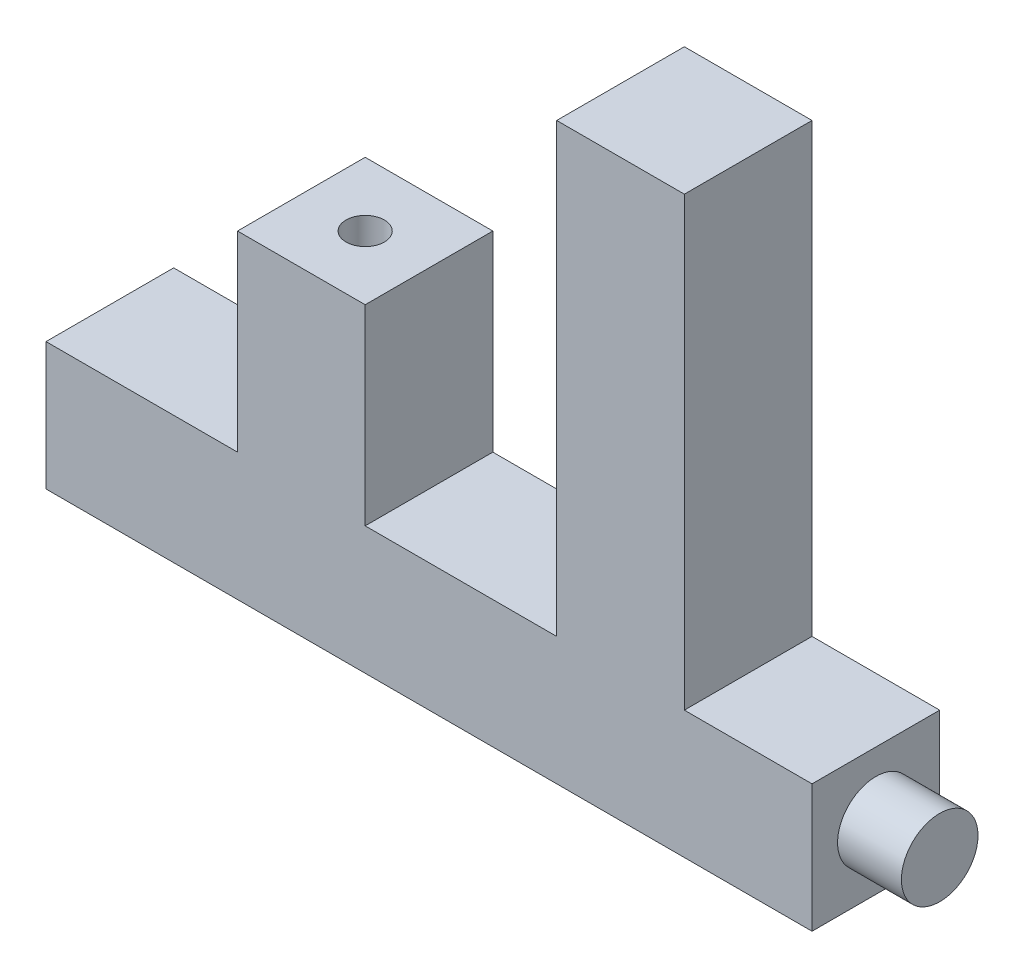
from build123d import *

# Parameters (mm, degrees)
EXTRUDE1_DEPTH     = 20
SKETCH2_R          = 3
CUT_EXTRUDE2_DEPTH = 10
SKETCH3_OUTSIDE_W  = 53.874
SKETCH3_OUTSIDE_H  = 123.874
SKETCH3_OUTSIDE_R  = 6
CUT_EXTRUDE3_DEPTH = 10


with BuildPart() as part:
    # Sketch1 → Extrude1 (new body)
    with BuildSketch(Plane.XY):
        Polygon((30, 50), (50, 50), (50, 20), (80, 20), (80, 90), (100, 90), (100, 20), (130, 20), (130, 0), (0, 0), (0, 20), (30, 20), align=None)
    extrude(amount=EXTRUDE1_DEPTH)

    # Sketch2 → Cut-Extrude2 (cut)
    with BuildSketch(Plane(origin=(0, 50, 0), x_dir=(-1, 0, 0), z_dir=(0, 1, 0))):
        with Locations(Location((-40, 10, 0), (0, 0, 90))):  # turned: the seam where the file's is
            Circle(SKETCH2_R)
    extrude(amount=-CUT_EXTRUDE2_DEPTH, mode=Mode.SUBTRACT)

    # Sketch3 outside → Cut-Extrude3 (cut)
    with BuildSketch(Plane(origin=(130, 0, 0), x_dir=(0, 0, -1), z_dir=(1, 0, 0))):
        with Locations((-10, 45)):
            Rectangle(SKETCH3_OUTSIDE_W, SKETCH3_OUTSIDE_H)
        with Locations((-10, 10)):
            Circle(SKETCH3_OUTSIDE_R, mode=Mode.SUBTRACT)
    extrude(amount=-CUT_EXTRUDE3_DEPTH, mode=Mode.SUBTRACT)


solid = part.part
